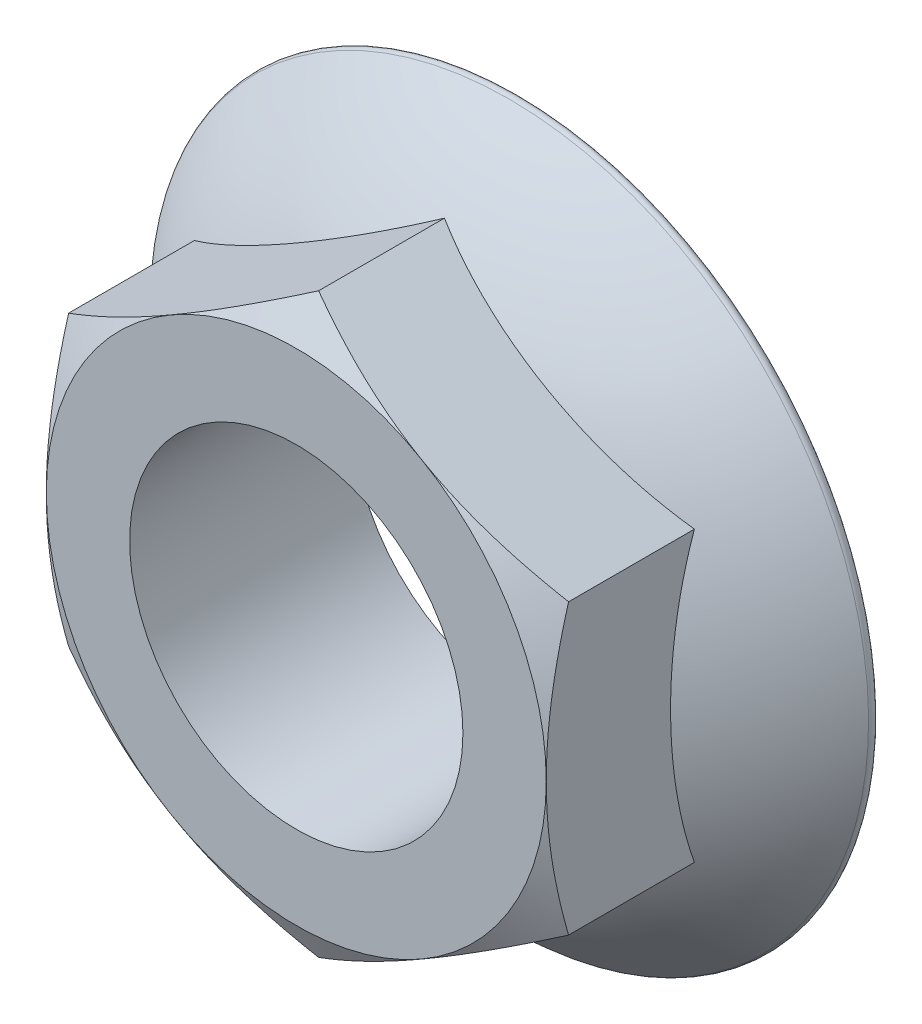
from build123d import *

# Parameters (mm, degrees)
BOSS_EXTRUDE1_DEPTH = 20
SKETCH5_OUTSIDE_W   = 154.97
SKETCH5_OUTSIDE_H   = 154.97
SKETCH5_OUTSIDE_R   = 22.5
CUT_EXTRUDE1_DEPTH  = 20
CUT_EXTRUDE1_TAPER  = 60
SKETCH6_R           = 15
CUT_EXTRUDE2_DEPTH  = 21


with BuildPart() as part:
    # Sketch1 → Boss-Extrude1 (new body)
    with BuildSketch(Plane.XY):
        Polygon((22.5, -12.990381057), (22.5, 12.990381057), (0, 25.980762114), (-22.5, 12.990381057), (-22.5, -12.990381057), (0, -25.980762114), align=None)
    extrude(amount=BOSS_EXTRUDE1_DEPTH)

    # Sketch2 → Revolve1 (revolve)
    with BuildSketch(Plane(origin=(0, 0, 0), x_dir=(0, 0, -1), z_dir=(1, 0, 0))):
        with BuildLine():
            Line((0, 0), (-12, 0))
            ThreePointArc((-12, 0), (-10.89665903, -17.717879555), (-0.820783292, -32.333533674))
            ThreePointArc((-0.820783292, -32.333533674), (-0.288330028, -32.402985456), (0, -31.95))
            Line((0, -31.95), (0, 0))
        make_face()
    revolve(axis=Axis((0, 0, 0), (0, 0, 1)))

    # Sketch5 outside → Cut-Extrude1 (cut)
    with BuildSketch(Plane.XY.offset(20)):
        Rectangle(SKETCH5_OUTSIDE_W, SKETCH5_OUTSIDE_H)
        Circle(SKETCH5_OUTSIDE_R, mode=Mode.SUBTRACT)
    extrude(amount=-CUT_EXTRUDE1_DEPTH, taper=CUT_EXTRUDE1_TAPER, mode=Mode.SUBTRACT)

    # Sketch6 → Cut-Extrude2 (cut, through all)
    with BuildSketch(Plane.XY.offset(20)):
        Circle(SKETCH6_R)
    extrude(amount=-CUT_EXTRUDE2_DEPTH, mode=Mode.SUBTRACT)


solid = part.part
